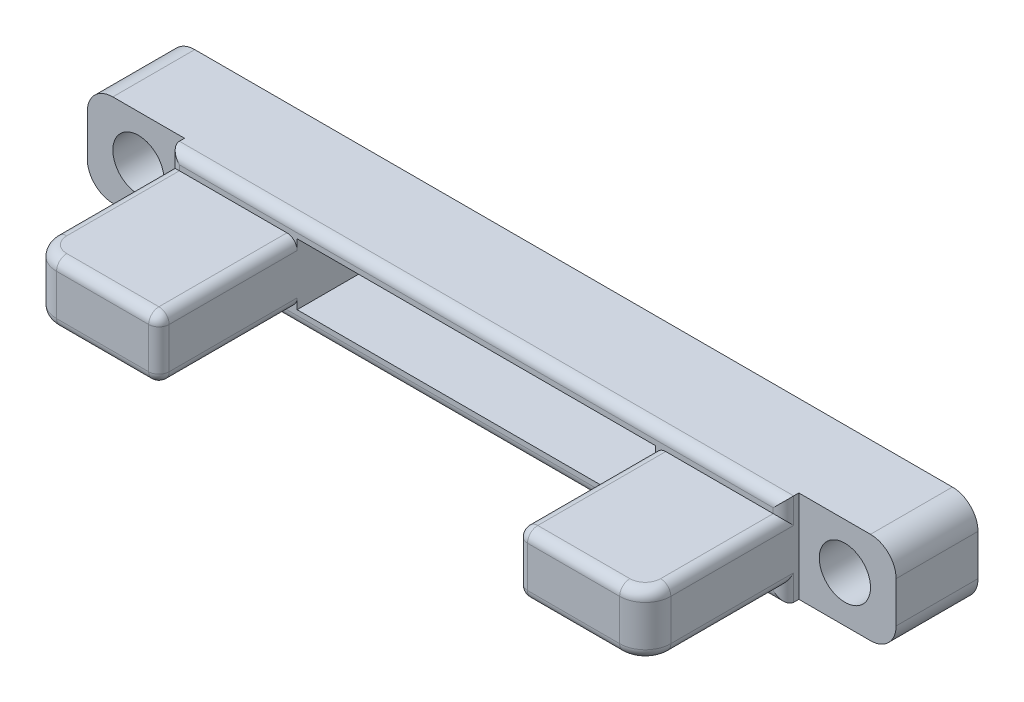
from build123d import *

# Parameters (mm, degrees)
SKETCH1_W           = 79
SKETCH1_H           = 9
SKETCH1_R           = 2.5
BOSS_EXTRUDE1_DEPTH = 8
SKETCH2_W           = 60
SKETCH2_H           = 6
BOSS_EXTRUDE2_DEPTH = 15
SKETCH3_W           = 1.5
SKETCH3_H           = 1.5
BOSS_EXTRUDE3_DEPTH = 60
SKETCH4_W           = 35
SKETCH4_H           = 6
CUT_EXTRUDE1_DEPTH  = 23
FILLET1_R           = 2.5
FILLET2_R           = 1


with BuildPart() as part:
    # Sketch1 → Boss-Extrude1 (new body)
    with BuildSketch(Plane.XY):
        Rectangle(SKETCH1_W, SKETCH1_H)
        with Locations((-34.5, 0)):
            Circle(SKETCH1_R, mode=Mode.SUBTRACT)
        with Locations((34.5, 0)):
            Circle(SKETCH1_R, mode=Mode.SUBTRACT)
    extrude(amount=BOSS_EXTRUDE1_DEPTH)

    # Sketch2 → Boss-Extrude2 (add)
    with BuildSketch(Plane.XY.offset(8)):
        Rectangle(SKETCH2_W, SKETCH2_H)
    extrude(amount=BOSS_EXTRUDE2_DEPTH)

    # Sketch3 → Boss-Extrude3 (add)
    with BuildSketch(Plane.ZY.offset(30)):
        with Locations((8.75, -3.75)):
            Rectangle(SKETCH3_W, SKETCH3_H)
        with Locations((8.75, 3.75)):
            Rectangle(SKETCH3_W, SKETCH3_H)
    extrude(amount=-BOSS_EXTRUDE3_DEPTH)

    # Sketch4 → Cut-Extrude1 (cut)
    with BuildSketch(Plane(origin=(0, 0, 23), x_dir=(-1, 0, 0), z_dir=(0, 0, -1))):
        Rectangle(SKETCH4_W, SKETCH4_H)
    extrude(amount=CUT_EXTRUDE1_DEPTH, mode=Mode.SUBTRACT)

    # Fillet1
    fillet1_edges = [part.edges().sort_by_distance(p)[0] for p in [
        (39.5, -4.5, 4),
        (-39.5, -4.5, 4),
        (-39.5, 4.5, 4),
        (39.5, 4.5, 4),
        (30, 0, 23),
        (-30, 0, 23),
    ]]
    fillet(fillet1_edges, radius=FILLET1_R)

    # Fillet2
    fillet2_edges = [part.edges().sort_by_distance(p)[0] for p in [
        (0, 4.5, 9.5),
        (-30, 3.75, 9.5),
        (30, 3.75, 9.5),
        (0, -4.5, 9.5),
        (-30, -3.75, 9.5),
        (30, -3.75, 9.5),
        (-22.5, 3, 23),
        (22.5, -3, 23),
        (-17.5, 3, 16.25),
        (17.5, -3, 16.25),
        (-17.5, 0, 23),
        (17.5, 3, 16.25),
        (17.5, 0, 23),
        (-17.5, -3, 16.25),
        (22.5, 3, 23),
        (30, 3, 15),
        (29.267766953, 3, 22.267766953),
        (30, -3, 15),
        (29.267766953, -3, 22.267766953),
        (-22.5, -3, 23),
        (-30, -3, 15),
        (-29.267766953, -3, 22.267766953),
        (-30, 3, 15),
        (-29.267766953, 3, 22.267766953),
    ]]
    fillet(fillet2_edges, radius=FILLET2_R)


solid = part.part
